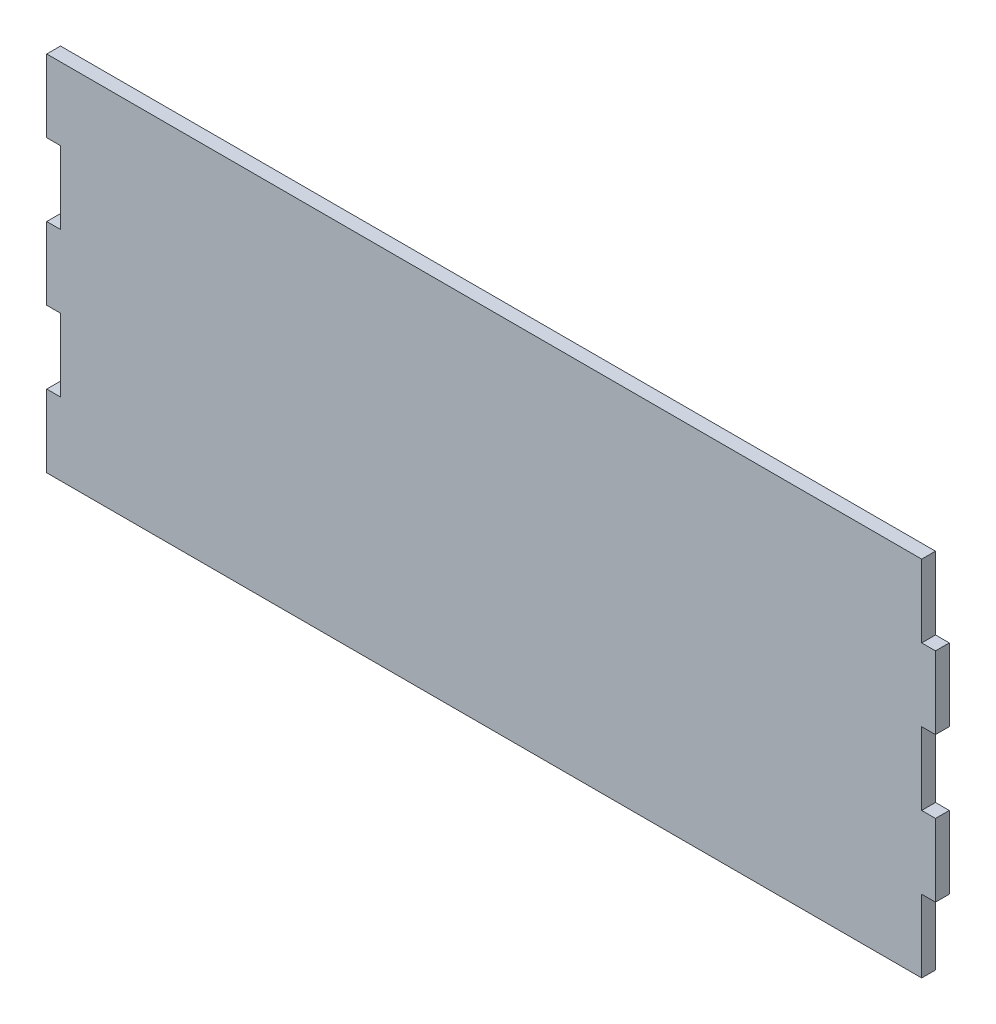
from build123d import *

# Parameters (mm, degrees)
BOSS_EXTRUDE1_DEPTH = 4.826


with BuildPart() as part:
    # Sketch1 → Boss-Extrude1 (new body)
    with BuildSketch(Plane.XY):
        Polygon((-306.324, 101.6), (-306.324, 127), (0, 127), (0, 101.6), (4.826, 101.6), (4.826, 76.2), (0, 76.2), (0, 50.8), (4.826, 50.8), (4.826, 25.4), (0, 25.4), (0, 0), (-306.324, 0), (-306.324, 25.4), (-301.498, 25.4), (-301.498, 50.8), (-306.324, 50.8), (-306.324, 76.2), (-301.498, 76.2), (-301.498, 101.6), align=None)
    extrude(amount=BOSS_EXTRUDE1_DEPTH)


solid = part.part
